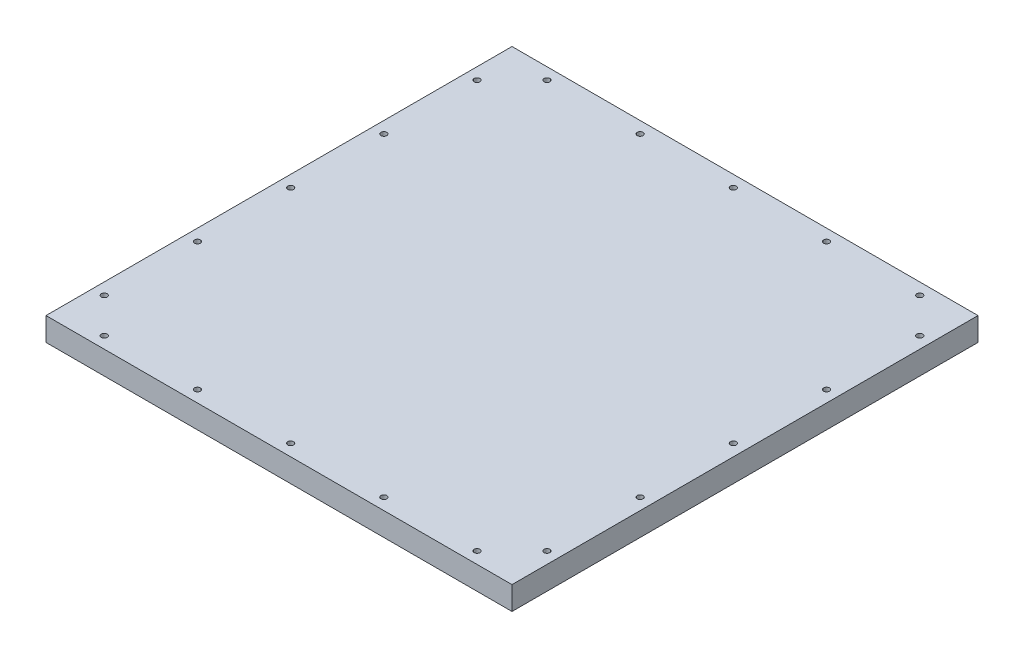
from build123d import *

# Parameters (mm, degrees)
SKETCH1_W           = 254
SKETCH1_H           = 254
SKETCH1_R           = 1.5875
BOSS_EXTRUDE1_DEPTH = 12.7


with BuildPart() as part:
    # Sketch1 → Boss-Extrude1 (new body)
    with BuildSketch(Plane(origin=(0, 0, 0), x_dir=(1, 0, 0), z_dir=(0, 1, 0))):
        with Locations((127, 127)):
            Rectangle(SKETCH1_W, SKETCH1_H)
        with Locations((6.35, 25.4)):
            Circle(SKETCH1_R, mode=Mode.SUBTRACT)
        with Locations((247.65, 25.4)):
            Circle(SKETCH1_R, mode=Mode.SUBTRACT)
        with Locations((6.35, 76.2)):
            Circle(SKETCH1_R, mode=Mode.SUBTRACT)
        with Locations((247.65, 76.2)):
            Circle(SKETCH1_R, mode=Mode.SUBTRACT)
        with Locations((6.35, 127)):
            Circle(SKETCH1_R, mode=Mode.SUBTRACT)
        with Locations((247.65, 127)):
            Circle(SKETCH1_R, mode=Mode.SUBTRACT)
        with Locations((6.35, 177.8)):
            Circle(SKETCH1_R, mode=Mode.SUBTRACT)
        with Locations((247.65, 177.8)):
            Circle(SKETCH1_R, mode=Mode.SUBTRACT)
        with Locations((6.35, 228.6)):
            Circle(SKETCH1_R, mode=Mode.SUBTRACT)
        with Locations((247.65, 228.6)):
            Circle(SKETCH1_R, mode=Mode.SUBTRACT)
        with Locations((25.4, 6.35)):
            Circle(SKETCH1_R, mode=Mode.SUBTRACT)
        with Locations((76.2, 6.35)):
            Circle(SKETCH1_R, mode=Mode.SUBTRACT)
        with Locations((127, 6.35)):
            Circle(SKETCH1_R, mode=Mode.SUBTRACT)
        with Locations((177.8, 6.35)):
            Circle(SKETCH1_R, mode=Mode.SUBTRACT)
        with Locations((228.6, 6.35)):
            Circle(SKETCH1_R, mode=Mode.SUBTRACT)
        with Locations((25.4, 247.65)):
            Circle(SKETCH1_R, mode=Mode.SUBTRACT)
        with Locations((76.2, 247.65)):
            Circle(SKETCH1_R, mode=Mode.SUBTRACT)
        with Locations((127, 247.65)):
            Circle(SKETCH1_R, mode=Mode.SUBTRACT)
        with Locations((177.8, 247.65)):
            Circle(SKETCH1_R, mode=Mode.SUBTRACT)
        with Locations((228.6, 247.65)):
            Circle(SKETCH1_R, mode=Mode.SUBTRACT)
    extrude(amount=BOSS_EXTRUDE1_DEPTH)


solid = part.part
